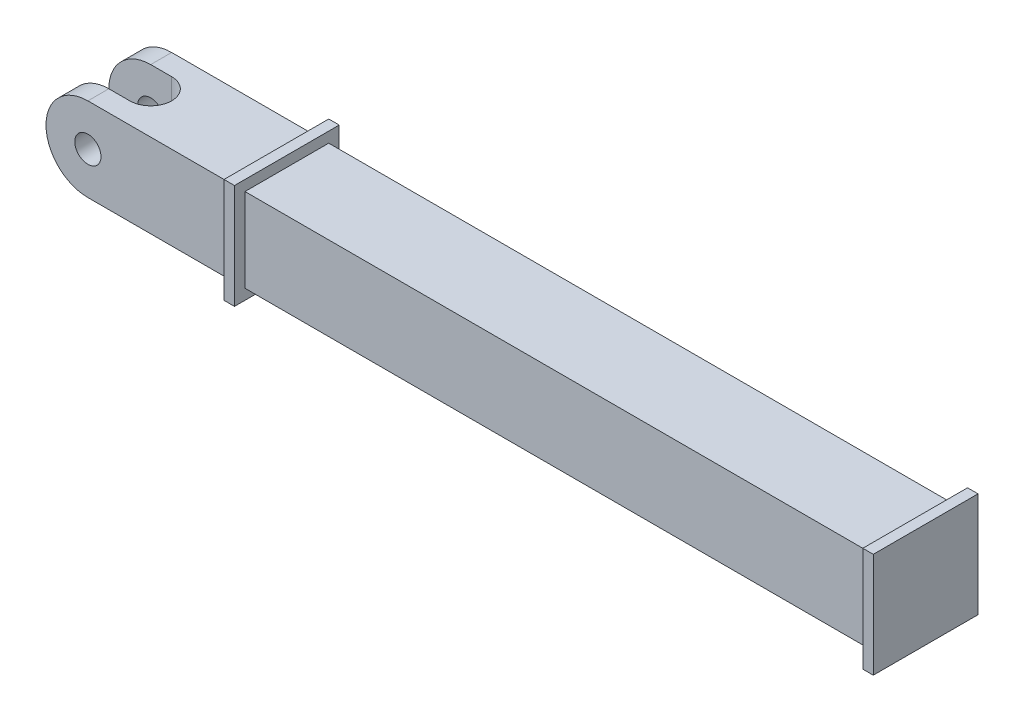
from build123d import *

# Parameters (mm, degrees)
SKETCH1_W           = 660
SKETCH1_H           = 80
BOSS_EXTRUDE1_DEPTH = 80
BOSS_EXTRUDE2_START = 320
SKETCH2_W           = 100
SKETCH2_H           = 100
BOSS_EXTRUDE2_DEPTH = 10
BOSS_EXTRUDE3_START = -280
SKETCH2_2_W         = 100
SKETCH2_2_H         = 100
BOSS_EXTRUDE3_DEPTH = 10
BOSS_EXTRUDE4_START = -290
SKETCH2_4_W         = 80
SKETCH2_4_H         = 80
BOSS_EXTRUDE4_DEPTH = 100
SKETCH4_R           = 12.5
BOSS_EXTRUDE5_DEPTH = 80
CUT_EXTRUDE1_DEPTH  = 80


with BuildPart() as part:
    # Sketch1 → Boss-Extrude1 (new body)
    with BuildSketch(Plane(origin=(0, 0, 0), x_dir=(1, 0, 0), z_dir=(0, 1, 0))):
        Rectangle(SKETCH1_W, SKETCH1_H)
    extrude(amount=BOSS_EXTRUDE1_DEPTH)

    # Sketch2 → Boss-Extrude2 (add)
    with BuildSketch(Plane(origin=(0, 0, 0), x_dir=(0, 0, -1), z_dir=(1, 0, 0)).offset(BOSS_EXTRUDE2_START)):
        with Locations((0, 40)):
            Rectangle(SKETCH2_W, SKETCH2_H)
    extrude(amount=BOSS_EXTRUDE2_DEPTH)

    # Sketch2_2 → Boss-Extrude3 (add)
    with BuildSketch(Plane(origin=(0, 0, 0), x_dir=(0, 0, -1), z_dir=(1, 0, 0)).offset(BOSS_EXTRUDE3_START)):
        with Locations((0, 40)):
            Rectangle(SKETCH2_2_W, SKETCH2_2_H)
    extrude(amount=-BOSS_EXTRUDE3_DEPTH)

    # Sketch2_4 → Boss-Extrude4 (add)
    with BuildSketch(Plane(origin=(0, 0, 0), x_dir=(0, 0, -1), z_dir=(1, 0, 0)).offset(BOSS_EXTRUDE4_START)):
        with Locations((0, 40)):
            Rectangle(SKETCH2_4_W, SKETCH2_4_H)
    extrude(amount=-BOSS_EXTRUDE4_DEPTH)

    # Sketch4 → Boss-Extrude5 (add)
    with BuildSketch(Plane.XY.offset(40)):
        with BuildLine():
            Line((-430, 0), (-390, 0))
            Line((-390, 0), (-390, 80))
            Line((-390, 80), (-430, 80))
            ThreePointArc((-430, 80), (-470, 40), (-430, 0))
        make_face()
        with Locations((-430, 40)):
            Circle(SKETCH4_R, mode=Mode.SUBTRACT)
    extrude(amount=-BOSS_EXTRUDE5_DEPTH)

    # Sketch5 → Cut-Extrude1 (cut)
    with BuildSketch(Plane(origin=(0, 80, 0), x_dir=(1, 0, 0), z_dir=(0, 1, 0))):
        with BuildLine():
            Line((-470, 20), (-430, 20))
            Line((-430, 20), (-410, 20))
            ThreePointArc((-410, 20), (-390, 0), (-410, -20))
            Line((-410, -20), (-430, -20))
            Line((-430, -20), (-470, -20))
            Line((-470, -20), (-470, 20))
        make_face()
    extrude(amount=-CUT_EXTRUDE1_DEPTH, mode=Mode.SUBTRACT)


solid = part.part
